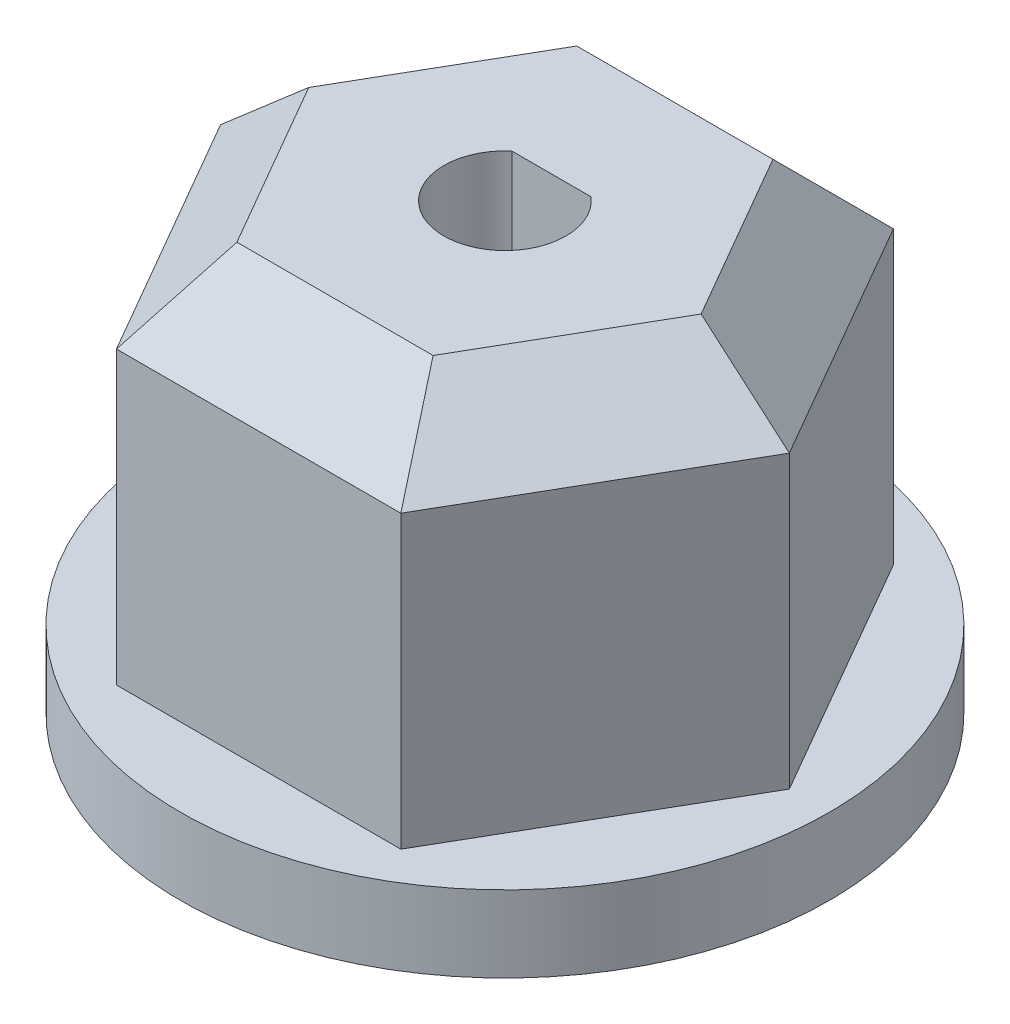
from build123d import *

# Parameters (mm, degrees)
BOSS_EXTRUDE1_DEPTH = 7.62
SKETCH2_R           = 8.5
BOSS_EXTRUDE2_DEPTH = 2
BOSS_EXTRUDE3_DEPTH = 2
CHAMFER1_SIZE       = 2
CHAMFER2_SIZE       = 1


with BuildPart() as part:
    # Sketch1 → Boss-Extrude1 (new body)
    with BuildSketch(Plane(origin=(0, 0, 0), x_dir=(1, 0, 0), z_dir=(0, 1, 0))):
        Polygon((3.723909236, 6.45), (-3.723909236, 6.45), (-7.447818473, 0), (-3.723909236, -6.45), (3.723909236, -6.45), (7.447818473, 0), align=None)
        with BuildLine():
            Line((-1.037493712, 1.218033989), (1.037493712, 1.218033989))
            ThreePointArc((1.037493712, 1.218033989), (0, -1.6), (-1.037493712, 1.218033989))
        make_face(mode=Mode.SUBTRACT)
    extrude(amount=BOSS_EXTRUDE1_DEPTH)

    # Sketch2 → Boss-Extrude2 (add)
    with BuildSketch(Plane.XZ):
        Circle(SKETCH2_R)
        with BuildLine():
            Line((1.037493712, -1.218033989), (-1.037493712, -1.218033989))
            ThreePointArc((-1.037493712, -1.218033989), (0, 1.6), (1.037493712, -1.218033989))
        make_face(mode=Mode.SUBTRACT)
    extrude(amount=BOSS_EXTRUDE2_DEPTH)

    # Sketch3 → Boss-Extrude3 (add)
    with BuildSketch(Plane(origin=(0, 7.62, 0), x_dir=(1, 0, 0), z_dir=(0, 1, 0))):
        Polygon((7.447818473, 0), (3.723909236, 6.45), (-3.723909236, 6.45), (-7.447818473, 0), (-3.723909236, -6.45), (3.723909236, -6.45), align=None)
        with BuildLine():
            Line((1.037493712, 1.218033989), (-1.037493712, 1.218033989))
            ThreePointArc((-1.037493712, 1.218033989), (0, -1.6), (1.037493712, 1.218033989))
        make_face(mode=Mode.SUBTRACT)
    extrude(amount=BOSS_EXTRUDE3_DEPTH)

    # Chamfer1
    chamfer1_edges = [part.edges().sort_by_distance(p)[0] for p in [
        (5.585863854, 9.62, 3.225),
        (5.585863854, 9.62, -3.225),
        (0, 9.62, -6.45),
        (-5.585863854, 9.62, -3.225),
        (-5.585863854, 9.62, 3.225),
        (0, 9.62, 6.45),
    ]]
    chamfer(chamfer1_edges, length=CHAMFER1_SIZE)

    # Chamfer2
    chamfer2_edges = [part.edges().sort_by_distance(p)[0] for p in [
        (0, -2, 1.6),
        (0, -2, -1.218033989),
    ]]
    chamfer(chamfer2_edges, length=CHAMFER2_SIZE)


solid = part.part
